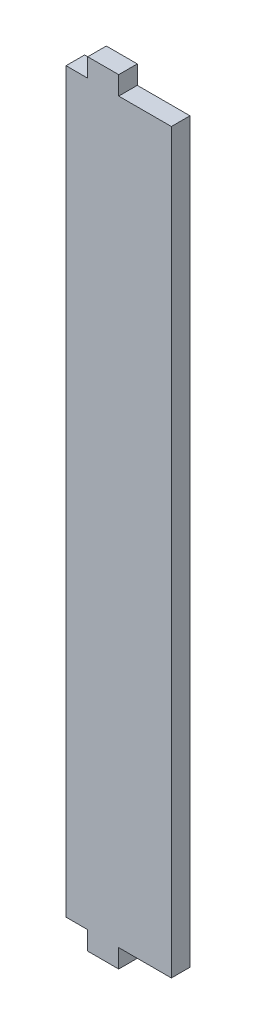
from build123d import *

# Parameters (mm, degrees)
ESQUISSE1_W        = 34
ESQUISSE1_H        = 238
BOSS_EXTRU_1_DEPTH = 6
ESQUISSE2_W        = 10
ESQUISSE2_H        = 6
BOSS_EXTRU_2_DEPTH = 6


with BuildPart() as part:
    # Esquisse1 → Boss.-Extru.1 (new body)
    with BuildSketch(Plane.XY):
        Rectangle(ESQUISSE1_W, ESQUISSE1_H)
    extrude(amount=BOSS_EXTRU_1_DEPTH)

    # Esquisse2 → Boss.-Extru.2 (add)
    with BuildSketch(Plane.XY.offset(6)):
        with Locations((-5, 122)):
            Rectangle(ESQUISSE2_W, ESQUISSE2_H)
        with Locations((-5, -122)):
            Rectangle(ESQUISSE2_W, ESQUISSE2_H)
    extrude(amount=-BOSS_EXTRU_2_DEPTH)


solid = part.part
